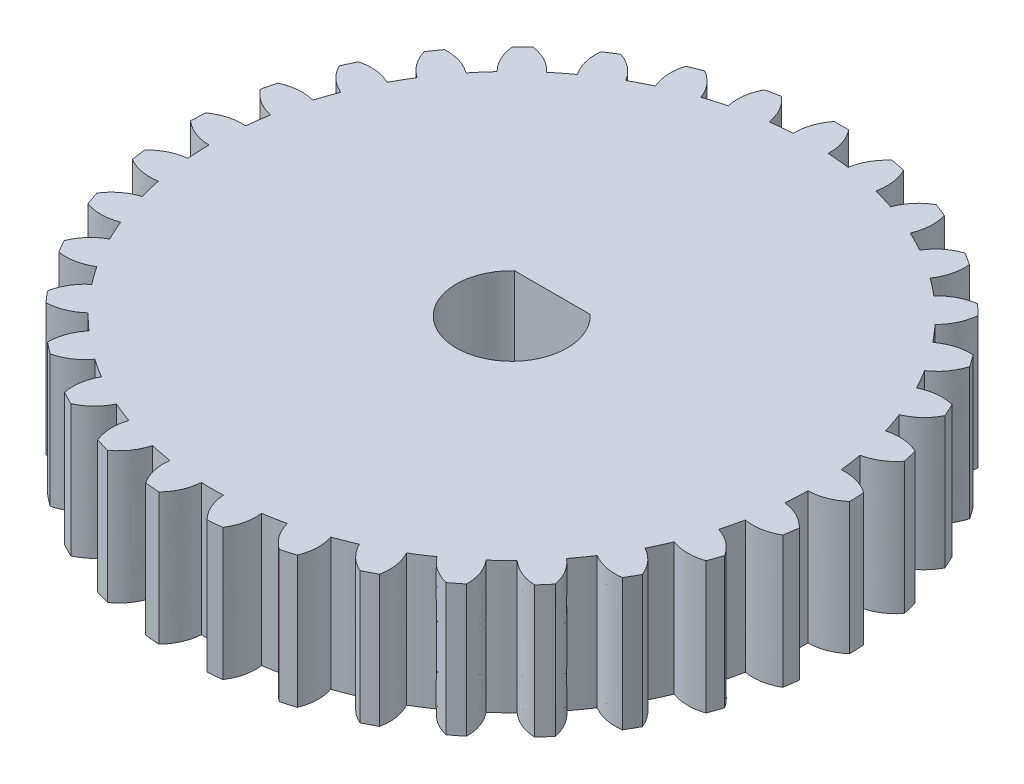
from build123d import *

# Parameters (mm, degrees)
BOSS_EXTRUDE1_DEPTH = 4.8
CIRPATTERN1_COUNT   = 33
CUT_EXTRUDE1_DEPTH  = 4.8


with BuildPart() as part:
    # Sketch1 → Boss-Extrude1 (new body)
    with BuildSketch(Plane(origin=(0, 0, 0), x_dir=(1, 0, 0), z_dir=(0, 1, 0))):
        with BuildLine():
            Line((0, 0), (1.044718702, 10.849818562))
            ThreePointArc((1.044718702, 10.849818562), (0.840979332, 10.867509087), (0.636943925, 10.881374106))
            add(Edge.make_bspline(
                [(0.636943925, 10.881374106), (0.649711285, 11.506147974), (0.265966398, 11.997052216)],
                knots=[0, 0, 0, 1, 1, 1], degree=2))
            ThreePointArc((0.265966398, 11.997052216), (0.132991366, 11.999263031), (0, 12))
            ThreePointArc((0, 12), (-0.132991366, 11.999263031), (-0.265966398, 11.997052216))
            add(Edge.make_bspline(
                [(-0.636943925, 10.881374106), (-0.649711285, 11.506147974), (-0.265966398, 11.997052216)],
                knots=[0, 0, 0, 1, 1, 1], degree=2))
            ThreePointArc((-0.636943925, 10.881374106), (-0.840979332, 10.867509087), (-1.044718702, 10.849818562))
            Line((-1.044718702, 10.849818562), (0, 0))
        make_face()
    boss_extrude1 = extrude(amount=BOSS_EXTRUDE1_DEPTH)

    # CirPattern1: Boss-Extrude1 ×33 about axis
    cirpattern1_axis = Axis((0, 3.675, 0), (0, -1, 0))
    for i in range(1, CIRPATTERN1_COUNT):
        add(boss_extrude1.rotate(cirpattern1_axis, i * 360 / CIRPATTERN1_COUNT))

    # Sketch9 → Cut-Extrude1 (cut)
    with BuildSketch(Plane(origin=(0, 4.8, 0), x_dir=(1, 0, 0), z_dir=(0, 1, 0))):
        with BuildLine():
            Line((-1.375, 1.479788836), (1.375, 1.479788836))
            ThreePointArc((1.375, 1.479788836), (0, -2.02), (-1.375, 1.479788836))
        make_face()
    extrude(amount=-CUT_EXTRUDE1_DEPTH, mode=Mode.SUBTRACT)


solid = part.part
